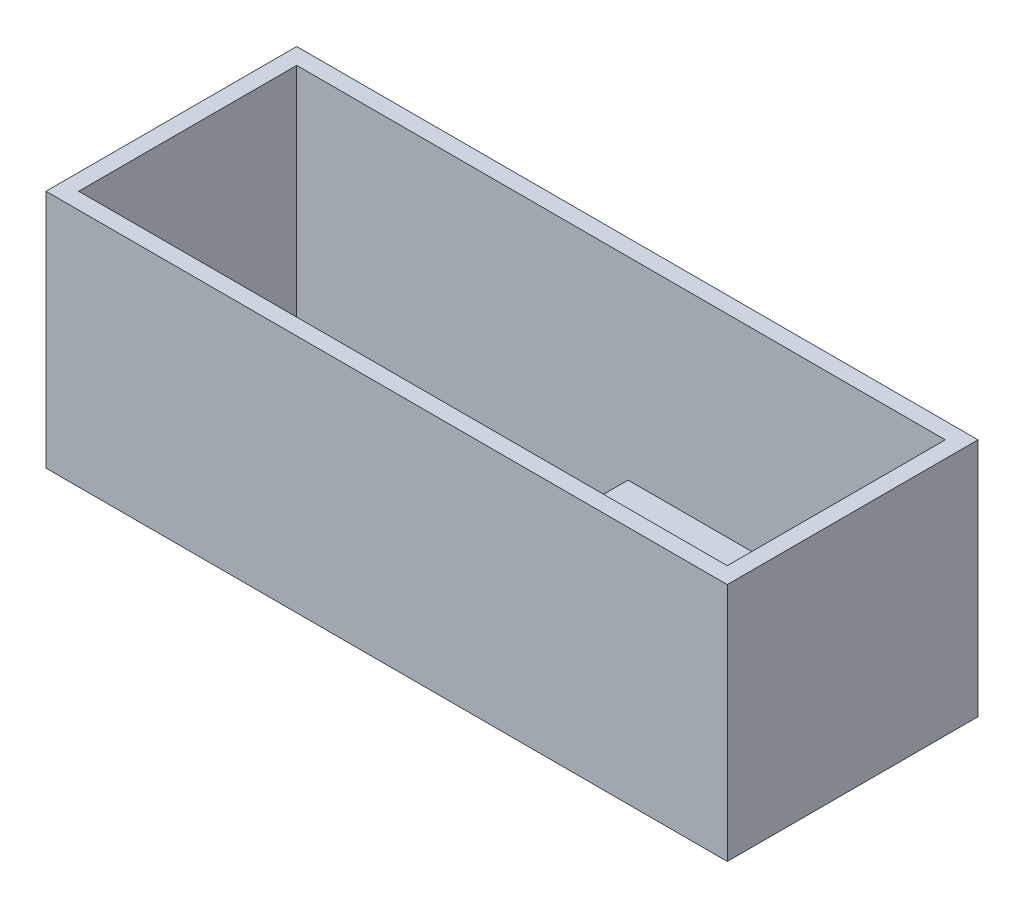
from build123d import *

# Parameters (mm, degrees)
SKETCH1_W           = 119
SKETCH1_H           = 40
BOSS_EXTRUDE1_DEPTH = 4
SKETCH2_W           = 125
SKETCH2_H           = 46
SKETCH2_W_2         = 119
SKETCH2_H_2         = 40
BOSS_EXTRUDE2_DEPTH = 44
SKETCH3_W           = 58.2
SKETCH3_H           = 40
BOSS_EXTRUDE3_DEPTH = 3
SKETCH4_W           = 28
SKETCH4_H           = 40
BOSS_EXTRUDE4_DEPTH = 1.5


with BuildPart() as part:
    # Sketch1 → Boss-Extrude1 (new body)
    with BuildSketch(Plane(origin=(0, 0, 0), x_dir=(1, 0, 0), z_dir=(0, 1, 0))):
        Rectangle(SKETCH1_W, SKETCH1_H)
    extrude(amount=BOSS_EXTRUDE1_DEPTH)

    # Sketch2 → Boss-Extrude2 (add)
    with BuildSketch(Plane(origin=(0, 0, 0), x_dir=(1, 0, 0), z_dir=(0, 1, 0))):
        Rectangle(SKETCH2_W, SKETCH2_H)
        Rectangle(SKETCH2_W_2, SKETCH2_H_2, mode=Mode.SUBTRACT)
    extrude(amount=BOSS_EXTRUDE2_DEPTH)

    # Sketch3 → Boss-Extrude3 (add)
    with BuildSketch(Plane(origin=(0, 4, 0), x_dir=(1, 0, 0), z_dir=(0, 1, 0))):
        with Locations((30.4, 0)):
            Rectangle(SKETCH3_W, SKETCH3_H)
    extrude(amount=BOSS_EXTRUDE3_DEPTH)

    # Sketch4 → Boss-Extrude4 (add)
    with BuildSketch(Plane(origin=(0, 7, 0), x_dir=(1, 0, 0), z_dir=(0, 1, 0))):
        with Locations((15.3, 0)):
            Rectangle(SKETCH4_W, SKETCH4_H)
    extrude(amount=BOSS_EXTRUDE4_DEPTH)


solid = part.part
